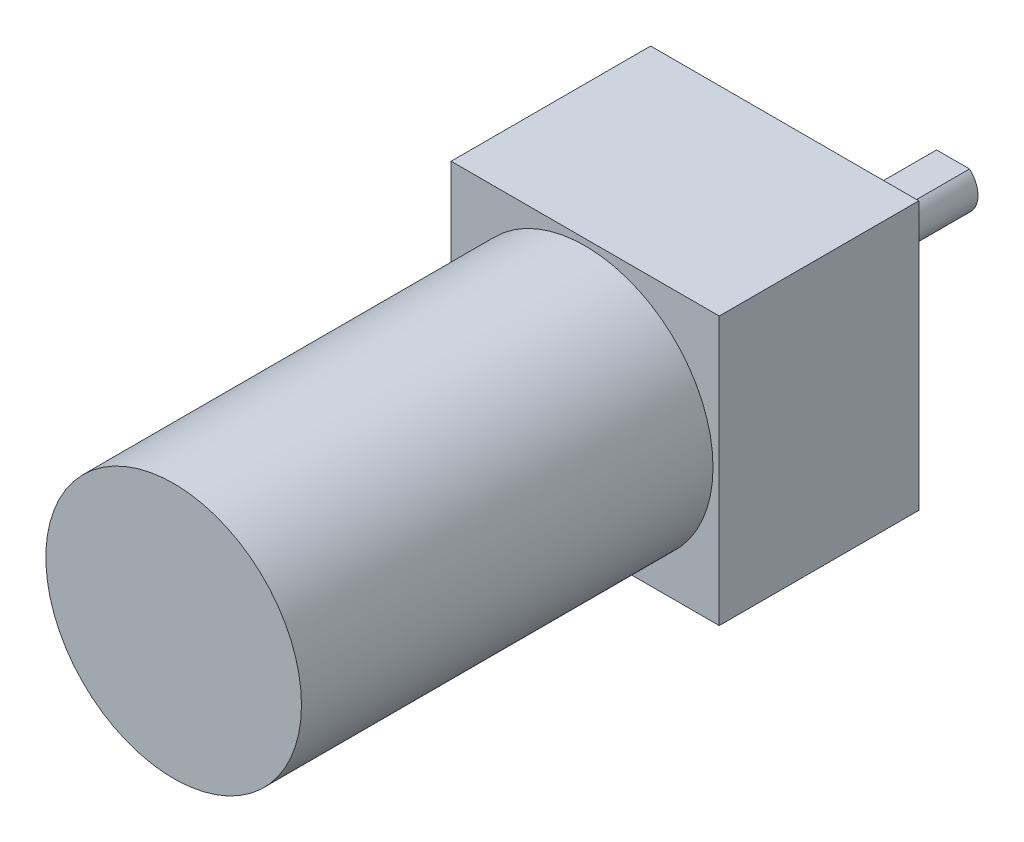
from build123d import *

# Parameters (mm, degrees)
SKETCH_1_W          = 43
SKETCH_1_H          = 43
EXTRUDE_1_DEPTH     = 32
SKETCH_5_W          = 10.30081486
SKETCH_5_H          = 4.860243631
CUT_EXTRUDE_1_DEPTH = 18
SKETCH_6_R          = 20.5
EXTRUDE_2_DEPTH     = 66
SKETCH_7_R          = 2
CUT_EXTRUDE_2_DEPTH = 30


with BuildPart() as part:
    # 草图1 → 凸台-拉伸1 (new body)
    with BuildSketch(Plane.XY):
        Rectangle(SKETCH_1_W, SKETCH_1_H)
    extrude(amount=EXTRUDE_1_DEPTH)

    # 草图4 → 旋转1 (revolve)
    with BuildSketch(Plane(origin=(0, 0, 0), x_dir=(0, 0, -1), z_dir=(1, 0, 0))):
        Polygon((0, 0), (0, 7), (7, 7), (7, 4), (27, 4), (27, 0), align=None)
    revolve(axis=Axis((0, 0, -27), (0, 0, 1)))

    # 草图5 → 切除-拉伸1 (cut)
    with BuildSketch(Plane(origin=(0, 0, -27), x_dir=(-1, 0, 0), z_dir=(0, 0, -1))):
        with Locations((0.230133924, 5.430121815)):
            Rectangle(SKETCH_5_W, SKETCH_5_H)
    extrude(amount=-CUT_EXTRUDE_1_DEPTH, mode=Mode.SUBTRACT)

    # 草图6 → 凸台-拉伸2 (add)
    with BuildSketch(Plane.XY.offset(32)):
        Circle(SKETCH_6_R)
    extrude(amount=EXTRUDE_2_DEPTH)

    # 草图7 → 切除-拉伸2 (cut)
    with BuildSketch(Plane(origin=(0, 0, 0), x_dir=(-1, 0, 0), z_dir=(0, 0, -1))):
        with Locations((-18, 18)):
            Circle(SKETCH_7_R)
        with Locations((18, 18)):
            Circle(SKETCH_7_R)
        with Locations((18, -18)):
            Circle(SKETCH_7_R)
        with Locations((-18, -18)):
            Circle(SKETCH_7_R)
    extrude(amount=-CUT_EXTRUDE_2_DEPTH, mode=Mode.SUBTRACT)


solid = part.part
